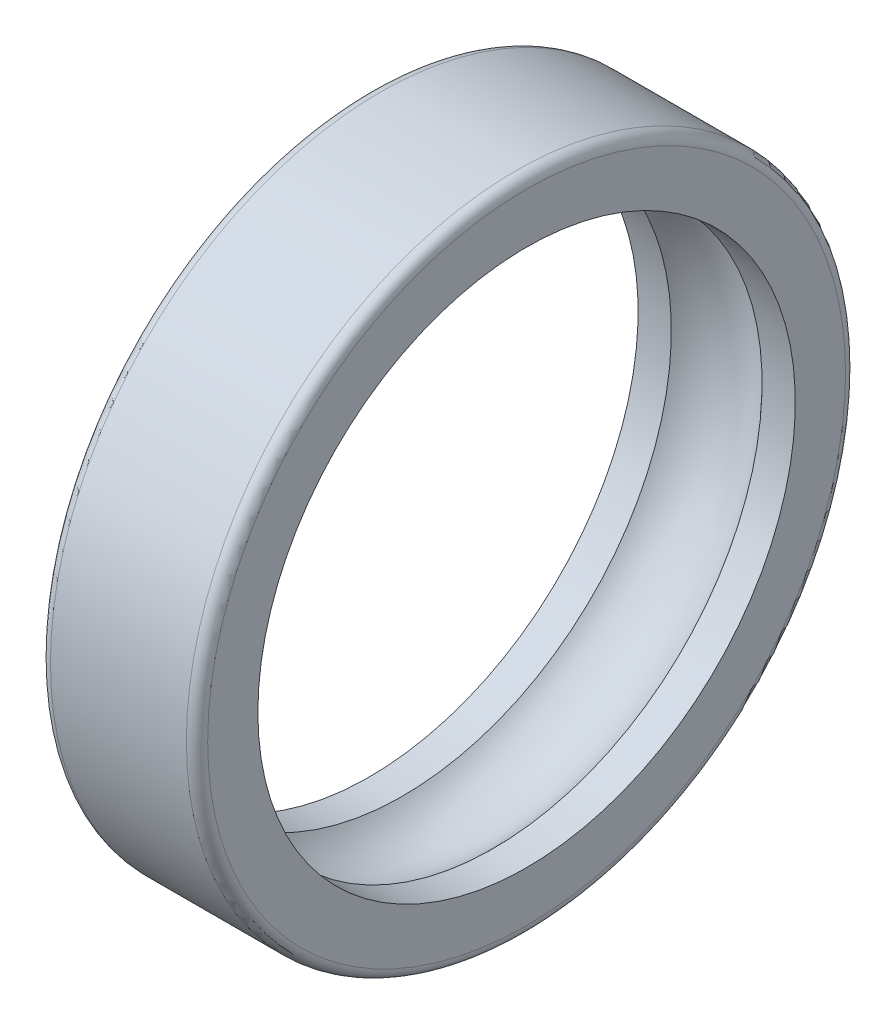
from build123d import *

# Parameters (mm, degrees)
FILLET1_R = 2.1


with BuildPart() as part:
    # Sketch3 → Revolve1 (revolve)
    with BuildSketch(Plane.XY):
        with BuildLine():
            Line((-15.339778092, 53), (-8.784050002, 53))
            ThreePointArc((-8.784050002, 53), (0.160221908, 57), (9.104493818, 53))
            Line((9.104493818, 53), (15.660221908, 53))
            Line((15.660221908, 53), (15.660221908, 65))
            Line((15.660221908, 65), (-15.339778092, 65))
            Line((-15.339778092, 65), (-15.339778092, 53))
        make_face()
    revolve(axis=Axis((-16.039993209, 0, 0), (1, 0, 0)))

    # Fillet1
    fillet1_edges = [part.edges().sort_by_distance(p)[0] for p in [
        (15.660221908, -65, 0),
        (-15.339778092, -65, 0),
    ]]
    fillet(fillet1_edges, radius=FILLET1_R)


solid = part.part
